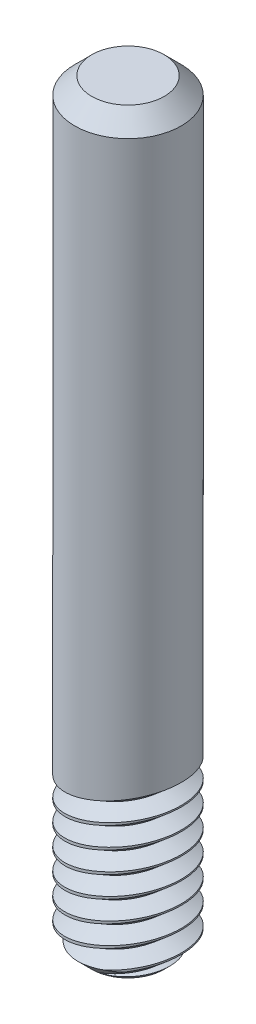
from build123d import *

# Parameters (mm, degrees)
SKETCH1_R            = 1.5875
BOSS_EXTRUDE1_DEPTH  = 22.5425
CHAMFER1_SIZE        = 0.508
LPATTERN1_COUNT      = 4
LPATTERN1_PITCH      = 0.635
LPATTERN1_COUNT_DIR2 = 2
LPATTERN1_PITCH_DIR2 = 2.54


with BuildPart() as part:
    # Sketch1 → Boss-Extrude1 (new body)
    with BuildSketch(Plane(origin=(0, 0, 0), x_dir=(1, 0, 0), z_dir=(0, 1, 0))):
        with Locations(Location((0, 0, 0), (0, 0, 270))):  # turned: the seam where the file's is
            Circle(SKETCH1_R)
    extrude(amount=BOSS_EXTRUDE1_DEPTH)

    # Chamfer1
    chamfer1_edges = [part.edges().sort_by_distance(p)[0] for p in [
        (0, 0, -1.5875),
        (0, 22.5425, -1.5875),
    ]]
    chamfer(chamfer1_edges, length=CHAMFER1_SIZE)

    # Sketch2 → Cut-Revolve1 (revolve, cut)
    with BuildSketch(Plane.XY):
        Polygon((1.5875, 0.635), (1.098757941, 0.211526079), (1.709868144, 0), align=None)
    cut_revolve1 = revolve(axis=Axis((0, 0, 0), (0.189224296, -0.981933891, 0)), mode=Mode.SUBTRACT)

    # LPattern1: Cut-Revolve1 4 × 2
    with Locations(*[Vector(0, 1, 0) * (i * LPATTERN1_PITCH) + Vector(0, 1, 0) * (j * LPATTERN1_PITCH_DIR2) for i in range(LPATTERN1_COUNT) for j in range(LPATTERN1_COUNT_DIR2) if (i, j) != (0, 0)]):
        add(cut_revolve1, mode=Mode.SUBTRACT)


solid = part.part
